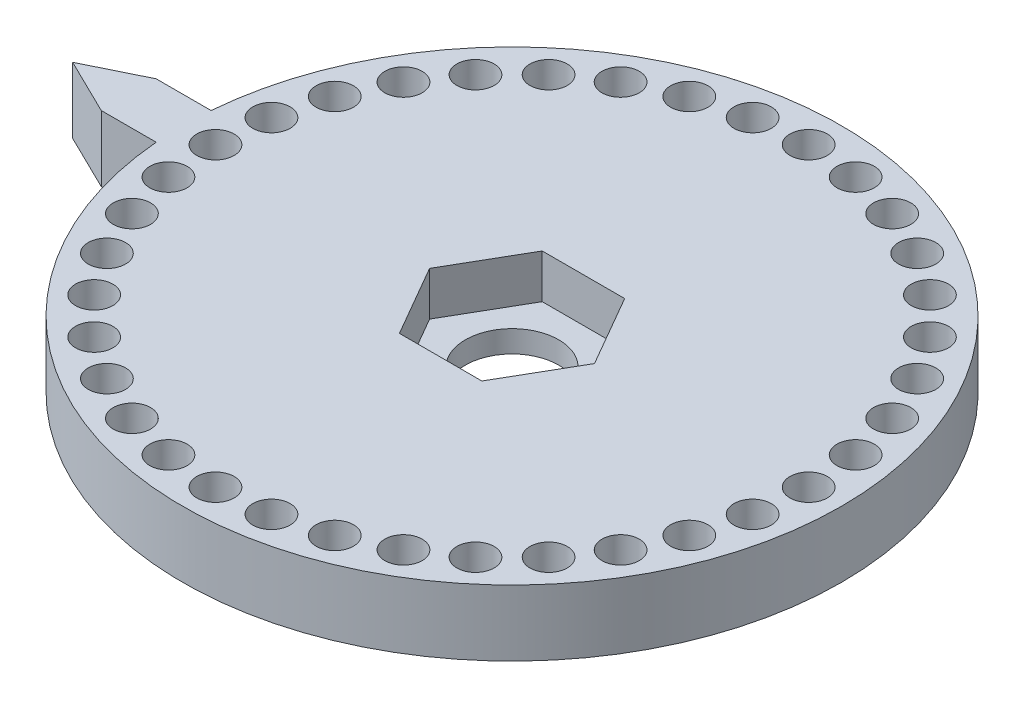
from build123d import *

# Parameters (mm, degrees)
SKETCH1_R           = 30
BOSS_EXTRUDE1_DEPTH = 6
CUT_EXTRUDE1_DEPTH  = 4
SKETCH3_R           = 1.7
CUT_EXTRUDE2_DEPTH  = 7
CIRPATTERN1_COUNT   = 36
SKETCH4_R           = 4.25
CUT_EXTRUDE3_DEPTH  = 3
BOSS_EXTRUDE2_DEPTH = 6


with BuildPart() as part:
    # Sketch1 → Boss-Extrude1 (new body)
    with BuildSketch(Plane(origin=(0, 0, 0), x_dir=(1, 0, 0), z_dir=(0, 1, 0))):
        Circle(SKETCH1_R)
    extrude(amount=BOSS_EXTRUDE1_DEPTH)

    # Sketch2 → Cut-Extrude1 (cut)
    with BuildSketch(Plane(origin=(0, 6, 0), x_dir=(1, 0, 0), z_dir=(0, 1, 0))):
        Polygon((3.75277675, 6.5), (-3.75277675, 6.5), (-7.505553499, 0), (-3.75277675, -6.5), (3.75277675, -6.5), (7.505553499, 0), align=None)
    extrude(amount=-CUT_EXTRUDE1_DEPTH, mode=Mode.SUBTRACT)

    # Sketch3 → Cut-Extrude2 (cut, through all)
    with BuildSketch(Plane(origin=(0, 6, 0), x_dir=(1, 0, 0), z_dir=(0, 1, 0))):
        with Locations((0, 27)):
            Circle(SKETCH3_R)
    cut_extrude2 = extrude(amount=-CUT_EXTRUDE2_DEPTH, mode=Mode.SUBTRACT)

    # CirPattern1: Cut-Extrude2 ×36 about axis
    cirpattern1_axis = Axis((0, 0, 0), (0, 1, 0))
    for i in range(1, CIRPATTERN1_COUNT):
        add(cut_extrude2.rotate(cirpattern1_axis, i * 360 / CIRPATTERN1_COUNT), mode=Mode.SUBTRACT)

    # Sketch4 → Cut-Extrude3 (cut, through all)
    with BuildSketch(Plane(origin=(0, 2, 0), x_dir=(1, 0, 0), z_dir=(0, 1, 0))):
        Circle(SKETCH4_R)
    extrude(amount=-CUT_EXTRUDE3_DEPTH, mode=Mode.SUBTRACT)

    # Sketch5 → Boss-Extrude2 (add)
    with BuildSketch(Plane(origin=(0, 6, 0), x_dir=(1, 0, 0), z_dir=(0, 1, 0))):
        Polygon((-34.895651858, 2.5), (-40, 0), (-34.895651858, -2.5), (-29.895651858, -2.5), (-29.895651858, 2.5), align=None)
    extrude(amount=-BOSS_EXTRUDE2_DEPTH)


solid = part.part
